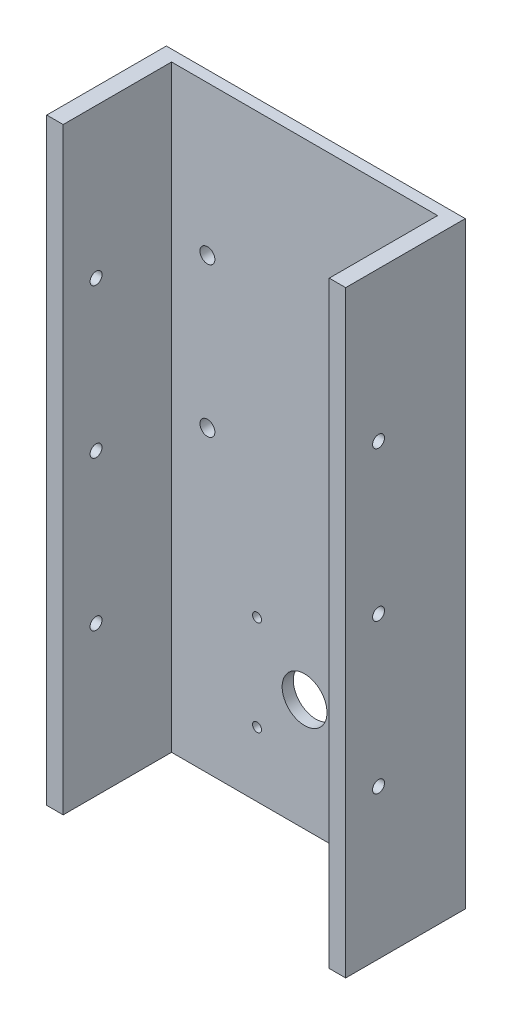
from build123d import *

# Parameters (mm, degrees)
SKETCH1_W           = 200
SKETCH1_H           = 400
SKETCH1_R           = 15
SKETCH1_R_2         = 5
BOSS_EXTRUDE1_DEPTH = 7.5
SKETCH4_W           = 11
SKETCH4_H           = 400
BOSS_EXTRUDE4_DEPTH = 72.5
SKETCH5_R           = 4
CUT_EXTRUDE1_DEPTH  = 200
SKETCH6_R           = 3
CUT_EXTRUDE2_DEPTH  = 10


with BuildPart() as part:
    # Sketch1 → Boss-Extrude1 (new body)
    with BuildSketch(Plane.XY):
        Rectangle(SKETCH1_W, SKETCH1_H)
        with Locations((0, -125)):
            Circle(SKETCH1_R, mode=Mode.SUBTRACT)
        with Locations((-65, 0)):
            Circle(SKETCH1_R_2, mode=Mode.SUBTRACT)
        with Locations((-65, 100)):
            Circle(SKETCH1_R_2, mode=Mode.SUBTRACT)
        with Locations((65, 100)):
            Circle(SKETCH1_R_2, mode=Mode.SUBTRACT)
        with Locations((65, 0)):
            Circle(SKETCH1_R_2, mode=Mode.SUBTRACT)
    extrude(amount=BOSS_EXTRUDE1_DEPTH)

    # Sketch4 → Boss-Extrude4 (add)
    with BuildSketch(Plane.XY.offset(7.5)):
        with Locations((-94.5, 0)):
            Rectangle(SKETCH4_W, SKETCH4_H)
        with Locations((94.5, 0)):
            Rectangle(SKETCH4_W, SKETCH4_H)
    extrude(amount=BOSS_EXTRUDE4_DEPTH)

    # Sketch5 → Cut-Extrude1 (cut)
    with BuildSketch(Plane(origin=(100, 0, 0), x_dir=(0, 0, -1), z_dir=(1, 0, 0))):
        with Locations((-58, 100)):
            Circle(SKETCH5_R)
        with Locations((-58, 0)):
            Circle(SKETCH5_R)
        with Locations((-58, -100)):
            Circle(SKETCH5_R)
    extrude(amount=-CUT_EXTRUDE1_DEPTH, mode=Mode.SUBTRACT)

    # Sketch6 → Cut-Extrude2 (cut)
    with BuildSketch(Plane.XY):
        with Locations((31.797314882, -93.202685118)):
            Circle(SKETCH6_R)
        with Locations((-31.797314882, -93.202685118)):
            Circle(SKETCH6_R)
        with Locations((-31.797314882, -156.797314882)):
            Circle(SKETCH6_R)
        with Locations((31.797314882, -156.797314882)):
            Circle(SKETCH6_R)
    extrude(amount=CUT_EXTRUDE2_DEPTH, mode=Mode.SUBTRACT)


solid = part.part
